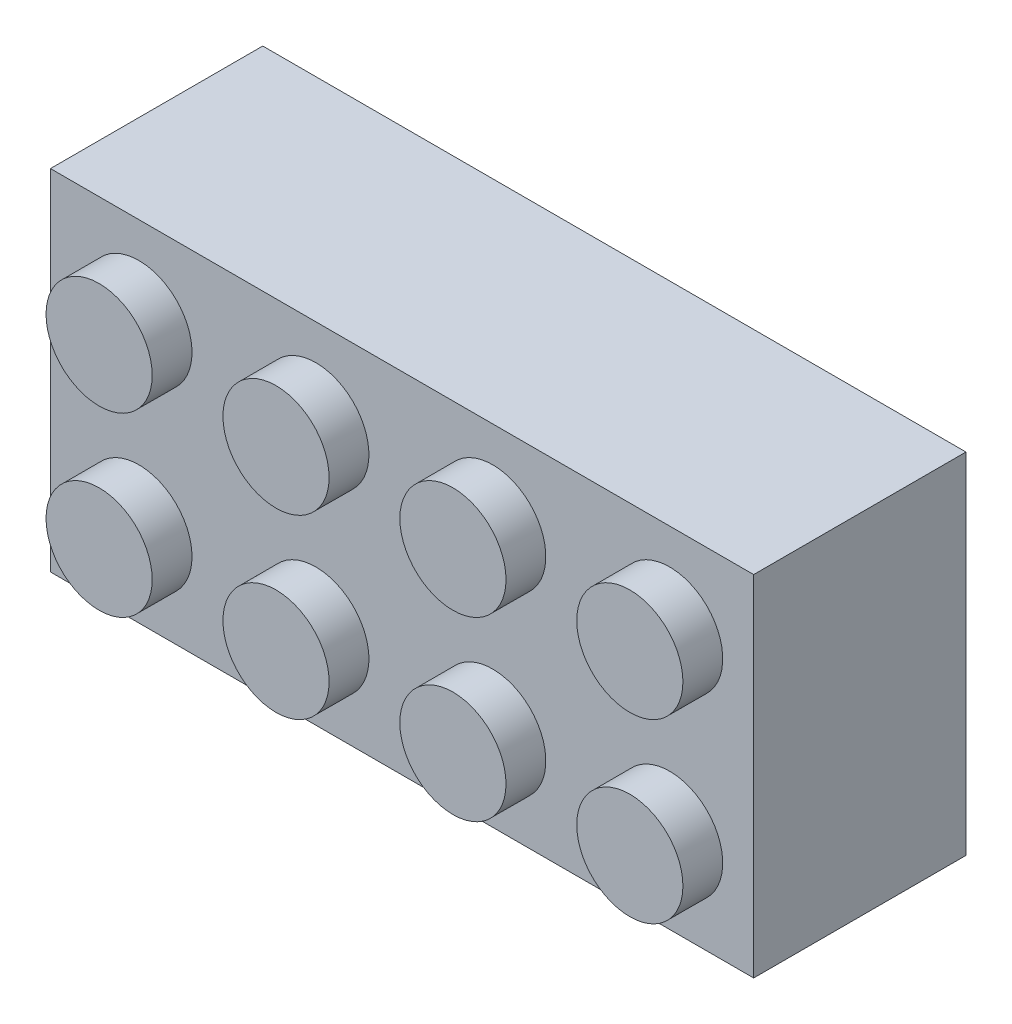
from build123d import *

# Parameters (mm, degrees)
SKETCH1_W           = 31.8
SKETCH1_H           = 15.8
BOSS_EXTRUDE1_DEPTH = 9.6
SKETCH2_R           = 2.4
BOSS_EXTRUDE2_DEPTH = 1.8
CUT_EXTRUDE1_START  = 0.7
SKETCH3_R           = 1.3
CUT_EXTRUDE1_DEPTH  = 20.7
SKETCH4_R           = 2.05
SKETCH4_R_2         = 3.25
CUT_EXTRUDE3_DEPTH  = 8.6
CUT_EXTRUDE4_DEPTH  = 2.3


with BuildPart() as part:
    # Sketch1 → Boss-Extrude1 (new body)
    with BuildSketch(Plane.XY):
        Rectangle(SKETCH1_W, SKETCH1_H)
    extrude(amount=BOSS_EXTRUDE1_DEPTH)

    # Sketch2 → Boss-Extrude2 (add)
    with BuildSketch(Plane.XY.offset(9.6)):
        with Locations(Location((-11.9, 3.9, 0), (0, 0, 180))):
            Circle(SKETCH2_R)
        with Locations(Location((-3.9, 3.9, 0), (0, 0, 180))):
            Circle(SKETCH2_R)
        with Locations(Location((4.1, 3.9, 0), (0, 0, 180))):
            Circle(SKETCH2_R)
        with Locations(Location((12.1, 3.9, 0), (0, 0, 180))):
            Circle(SKETCH2_R)
        with Locations(Location((-3.9, -4.1, 0), (0, 0, 180))):
            Circle(SKETCH2_R)
        with Locations(Location((4.1, -4.1, 0), (0, 0, 180))):
            Circle(SKETCH2_R)
        with Locations(Location((12.1, -4.1, 0), (0, 0, 180))):
            Circle(SKETCH2_R)
        with Locations(Location((-11.9, -4.1, 0), (0, 0, 180))):
            Circle(SKETCH2_R)
    extrude(amount=BOSS_EXTRUDE2_DEPTH)

    # Sketch3 → Cut-Extrude1 (cut)
    with BuildSketch(Plane.XY.offset(9.6).offset(CUT_EXTRUDE1_START)):
        with Locations((-11.9, 3.9)):
            Circle(SKETCH3_R)
        with Locations((-3.9, 3.9)):
            Circle(SKETCH3_R)
        with Locations((4.1, 3.9)):
            Circle(SKETCH3_R)
        with Locations((12.1, 3.9)):
            Circle(SKETCH3_R)
        with Locations((-3.9, -4.1)):
            Circle(SKETCH3_R)
        with Locations((4.1, -4.1)):
            Circle(SKETCH3_R)
        with Locations((12.1, -4.1)):
            Circle(SKETCH3_R)
        with Locations((-11.9, -4.1)):
            Circle(SKETCH3_R)
    extrude(amount=-CUT_EXTRUDE1_DEPTH, mode=Mode.SUBTRACT)

    # Sketch4 → Cut-Extrude3 (cut)
    with BuildSketch(Plane.XY):
        with Locations(Location((0, 0, 0), (0, 0, 180))):
            Circle(SKETCH4_R)
        with BuildLine():
            Line((-14.7, 3.4), (-14.7, -3.4))
            Line((-14.7, -3.4), (-14.5, -3.4))
            Line((-14.5, -3.4), (-14.5, -4.6))
            Line((-14.5, -4.6), (-14.7, -4.6))
            Line((-14.7, -4.6), (-14.7, -6.7))
            Line((-14.7, -6.7), (-12.6, -6.7))
            Line((-12.6, -6.7), (-12.6, -6.5))
            Line((-12.6, -6.5), (-11.4, -6.5))
            Line((-11.4, -6.5), (-11.4, -6.7))
            Line((-11.4, -6.7), (-4.6, -6.7))
            Line((-4.6, -6.7), (-4.6, -6.5))
            Line((-4.6, -6.5), (-3.4, -6.5))
            Line((-3.4, -6.5), (-3.4, -6.7))
            Line((-3.4, -6.7), (-0.55, -6.7))
            Line((-0.55, -6.7), (-0.55, -3.203123476))
            ThreePointArc((-0.55, -3.203123476), (-3.25, 0), (-0.55, 3.203123476))
            Line((-0.55, 3.203123476), (-0.55, 6.7))
            Line((-0.55, 6.7), (-3.4, 6.7))
            Line((-3.4, 6.7), (-3.4, 6.5))
            Line((-3.4, 6.5), (-4.6, 6.5))
            Line((-4.6, 6.5), (-4.6, 6.7))
            Line((-4.6, 6.7), (-11.4, 6.7))
            Line((-11.4, 6.7), (-11.4, 6.5))
            Line((-11.4, 6.5), (-12.6, 6.5))
            Line((-12.6, 6.5), (-12.6, 6.7))
            Line((-12.6, 6.7), (-14.7, 6.7))
            Line((-14.7, 6.7), (-14.7, 4.6))
            Line((-14.7, 4.6), (-14.5, 4.6))
            Line((-14.5, 4.6), (-14.5, 3.4))
            Line((-14.5, 3.4), (-14.7, 3.4))
        make_face()
        with Locations(Location((-8, 0, 0), (0, 0, 180))):
            Circle(SKETCH4_R_2, mode=Mode.SUBTRACT)
        with Locations(Location((-8, 0, 0), (0, 0, 180))):
            Circle(SKETCH4_R)
        with BuildLine():
            Line((0.55, -6.7), (0.55, -3.203123476))
            ThreePointArc((0.55, -3.203123476), (3.25, 0), (0.55, 3.203123476))
            Line((0.55, 3.203123476), (0.55, 6.7))
            Line((0.55, 6.7), (3.4, 6.7))
            Line((3.4, 6.7), (3.4, 6.5))
            Line((3.4, 6.5), (4.6, 6.5))
            Line((4.6, 6.5), (4.6, 6.7))
            Line((4.6, 6.7), (11.4, 6.7))
            Line((11.4, 6.7), (11.4, 6.5))
            Line((11.4, 6.5), (12.6, 6.5))
            Line((12.6, 6.5), (12.6, 6.7))
            Line((12.6, 6.7), (14.7, 6.7))
            Line((14.7, 6.7), (14.7, 4.6))
            Line((14.7, 4.6), (14.5, 4.6))
            Line((14.5, 4.6), (14.5, 3.4))
            Line((14.5, 3.4), (14.7, 3.4))
            Line((14.7, 3.4), (14.7, -3.4))
            Line((14.7, -3.4), (14.5, -3.4))
            Line((14.5, -3.4), (14.5, -4.6))
            Line((14.5, -4.6), (14.7, -4.6))
            Line((14.7, -4.6), (14.7, -6.7))
            Line((14.7, -6.7), (12.6, -6.7))
            Line((12.6, -6.7), (12.6, -6.5))
            Line((12.6, -6.5), (11.4, -6.5))
            Line((11.4, -6.5), (11.4, -6.7))
            Line((11.4, -6.7), (4.6, -6.7))
            Line((4.6, -6.7), (4.6, -6.5))
            Line((4.6, -6.5), (3.4, -6.5))
            Line((3.4, -6.5), (3.4, -6.7))
            Line((3.4, -6.7), (0.55, -6.7))
        make_face()
        with Locations(Location((8, 0, 0), (0, 0, 180))):
            Circle(SKETCH4_R_2, mode=Mode.SUBTRACT)
        with Locations(Location((8, 0, 0), (0, 0, 180))):
            Circle(SKETCH4_R)
    extrude(amount=CUT_EXTRUDE3_DEPTH, mode=Mode.SUBTRACT)

    # Sketch5 → Cut-Extrude4 (cut)
    with BuildSketch(Plane.XY):
        with BuildLine():
            Line((0.55, 6.7), (-0.55, 6.7))
            Line((-0.55, 6.7), (-0.55, 3.203123476))
            ThreePointArc((-0.55, 3.203123476), (0, 3.25), (0.55, 3.203123476))
            Line((0.55, 3.203123476), (0.55, 6.7))
        make_face()
        with BuildLine():
            Line((0.55, -6.7), (-0.55, -6.7))
            Line((-0.55, -6.7), (-0.55, -3.203123476))
            ThreePointArc((-0.55, -3.203123476), (0, -3.25), (0.55, -3.203123476))
            Line((0.55, -3.203123476), (0.55, -6.7))
        make_face()
    extrude(amount=CUT_EXTRUDE4_DEPTH, mode=Mode.SUBTRACT)


solid = part.part
